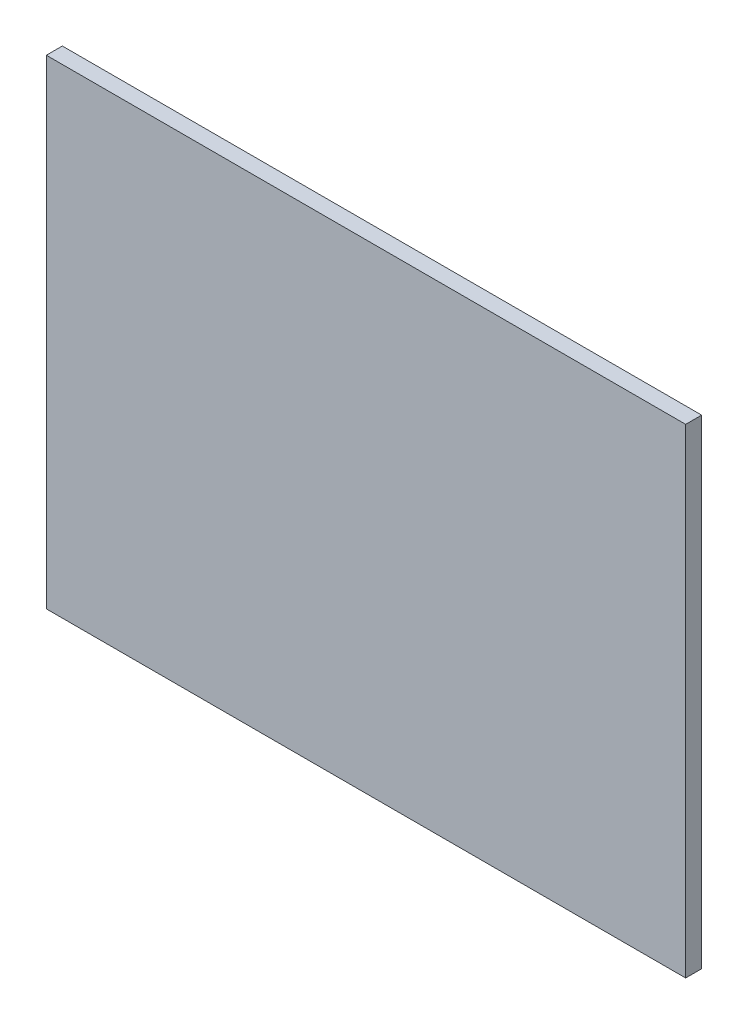
from build123d import *

# Parameters (mm, degrees)
SKETCH_1_W      = 400
SKETCH_1_H      = 300
EXTRUDE_1_DEPTH = 10


with BuildPart() as part:
    # 草图1 → 凸台-拉伸1 (new body)
    with BuildSketch(Plane.XY):
        with Locations((143.417429749, -126.262807225)):
            Rectangle(SKETCH_1_W, SKETCH_1_H)
    extrude(amount=EXTRUDE_1_DEPTH)


solid = part.part
